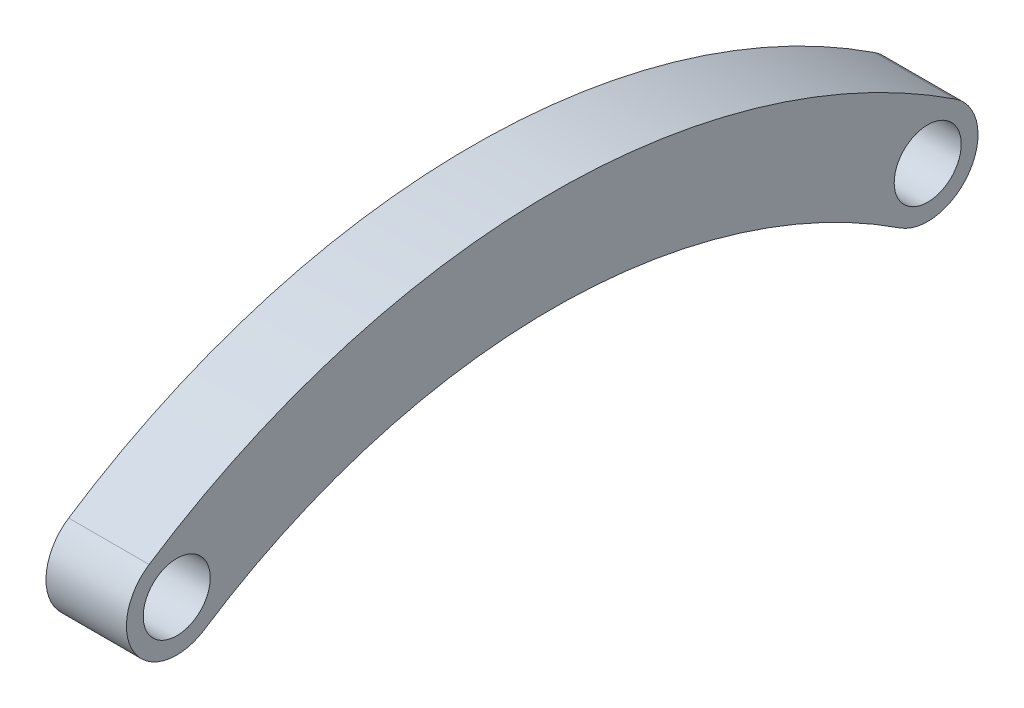
from build123d import *

# Parameters (mm, degrees)
BOSS_EXTRUDE1_DEPTH = 2.399999953
SKETCH2_R           = 2
CUT_EXTRUDE1_DEPTH  = 4.8


with BuildPart() as part:
    # Sketch1 → Boss-Extrude1 (new body, symmetric)
    with BuildSketch(Plane(origin=(0, 0, 0), x_dir=(0, 0, -1), z_dir=(1, 0, 0))):
        with BuildLine():
            ThreePointArc((0, 0), (10.830584713, -1.585060066), (20.752730266, -6.207289856))
            ThreePointArc((20.752730266, -6.207289856), (24.907289856, -5.347269734), (24.047269734, -1.192710144))
            ThreePointArc((24.047269734, -1.192710144), (12.549962758, 4.163308324), (0, 6))
            ThreePointArc((0, 6), (-12.549962758, 4.163308324), (-24.047269734, -1.192710144))
            ThreePointArc((-24.047269734, -1.192710144), (-24.907289856, -5.347269734), (-20.752730266, -6.207289856))
            ThreePointArc((-20.752730266, -6.207289856), (-10.830584713, -1.585060066), (0, 0))
        make_face()
    extrude(amount=BOSS_EXTRUDE1_DEPTH, both=True)

    # Sketch2 → Cut-Extrude1 (cut)
    with BuildSketch(Plane(origin=(2.399999953, 0, 0), x_dir=(0, 0, -1), z_dir=(1, 0, 0))):
        with Locations((-22.4, -3.7)):
            Circle(SKETCH2_R)
        with Locations((22.4, -3.7)):
            Circle(SKETCH2_R)
    extrude(amount=-CUT_EXTRUDE1_DEPTH, mode=Mode.SUBTRACT)


solid = part.part
